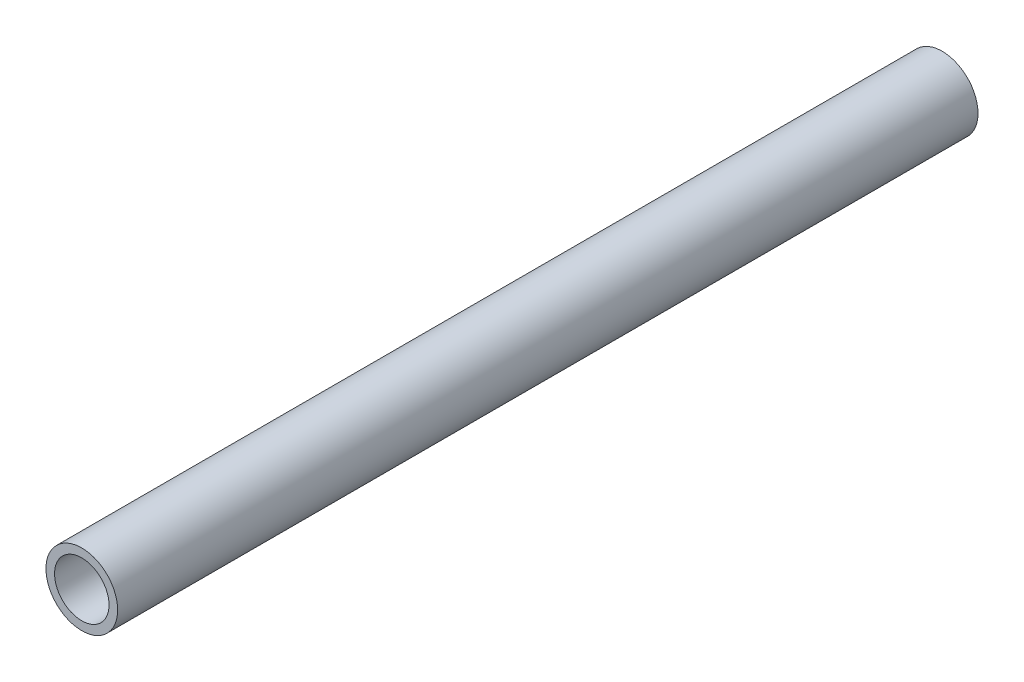
from build123d import *

# Parameters (mm, degrees)
ESQUISSE1_R        = 12.5
ESQUISSE1_R_2      = 9.5
BOSS_EXTRU_2_DEPTH = 300


with BuildPart() as part:
    # Esquisse1 → Boss.-Extru.2 (new body)
    with BuildSketch(Plane.XY):
        Circle(ESQUISSE1_R)
        Circle(ESQUISSE1_R_2, mode=Mode.SUBTRACT)
    extrude(amount=BOSS_EXTRU_2_DEPTH)


solid = part.part
